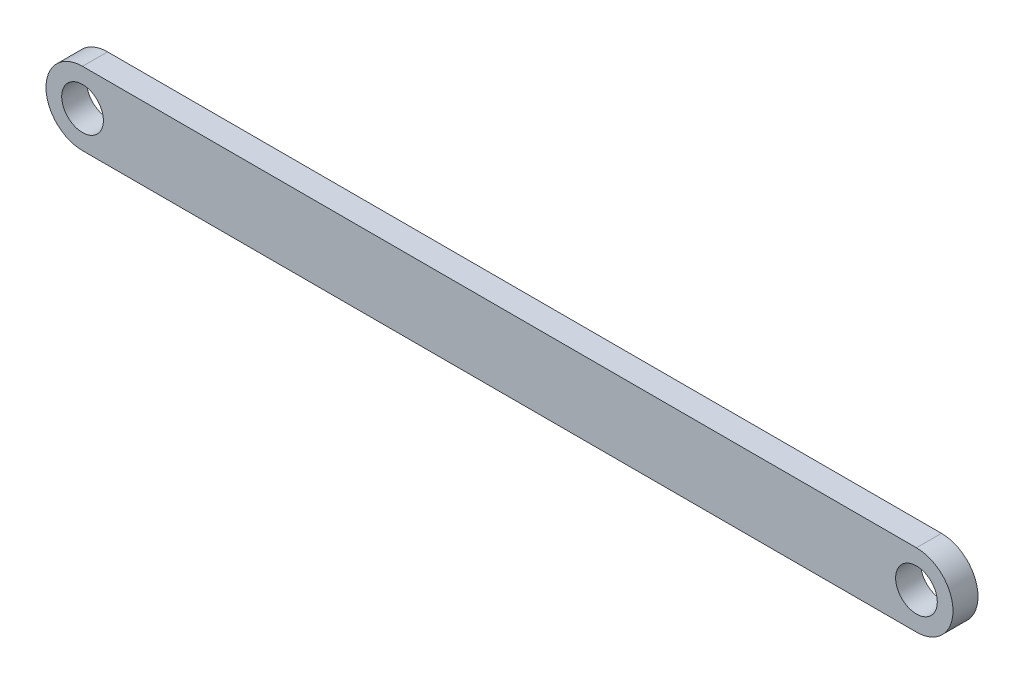
from build123d import *

# Parameters (mm, degrees)
CROQUIS1_R              = 5
SALIENTE_EXTRUIR1_DEPTH = 6


with BuildPart() as part:
    # Croquis1 → Saliente-Extruir1 (new body)
    with BuildSketch(Plane.XY):
        with BuildLine():
            Line((-32.675153403, 8.763083306), (167.324846597, 8.763083306))
            ThreePointArc((167.324846597, 8.763083306), (176.087929903, 0), (167.324846597, -8.763083306))
            Line((167.324846597, -8.763083306), (-32.675153403, -8.763083306))
            ThreePointArc((-32.675153403, -8.763083306), (-41.438236709, 0), (-32.675153403, 8.763083306))
        make_face()
        with Locations((-32.675153403, 0)):
            Circle(CROQUIS1_R, mode=Mode.SUBTRACT)
        with Locations((167.324846597, 0)):
            Circle(CROQUIS1_R, mode=Mode.SUBTRACT)
    extrude(amount=SALIENTE_EXTRUIR1_DEPTH)


solid = part.part
